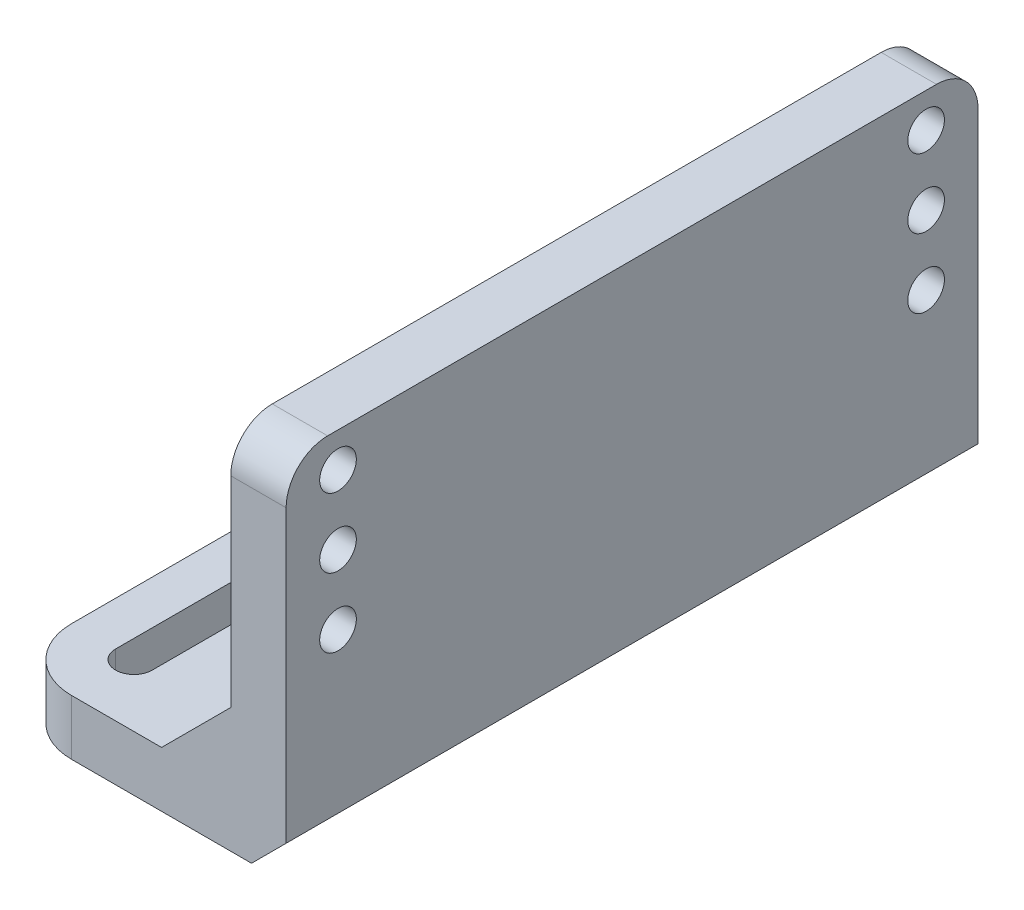
from build123d import *

# Parameters (mm, degrees)
SKETCH1_W           = 40
SKETCH1_H           = 100
BOSS_EXTRUDE1_DEPTH = 8
SKETCH2_W           = 100
SKETCH2_H           = 53
BOSS_EXTRUDE2_DEPTH = 8
SKETCH3_R           = 2.65
CUT_EXTRUDE1_DEPTH  = 9
FILLET1_R           = 6
CHAMFER2_SIZE       = 10
FILLET3_R           = 9
CUT_EXTRUDE3_DEPTH  = 9
CHAMFER1_SIZE       = 5


with BuildPart() as part:
    # Sketch1 → Boss-Extrude1 (new body)
    with BuildSketch(Plane(origin=(0, 0, 0), x_dir=(1, 0, 0), z_dir=(0, 1, 0))):
        with Locations((20, 50)):
            Rectangle(SKETCH1_W, SKETCH1_H)
    extrude(amount=BOSS_EXTRUDE1_DEPTH)

    # Sketch2 → Boss-Extrude2 (add)
    with BuildSketch(Plane.ZY):
        with Locations((-50, 26.5)):
            Rectangle(SKETCH2_W, SKETCH2_H)
    extrude(amount=-BOSS_EXTRUDE2_DEPTH)

    # Sketch3 → Cut-Extrude1 (cut, through all)
    with BuildSketch(Plane(origin=(8, 0, 0), x_dir=(0, 0, -1), z_dir=(1, 0, 0))):
        with Locations((7.5, 48)):
            Circle(SKETCH3_R)
        with Locations((92.5, 28)):
            Circle(SKETCH3_R)
        with Locations((92.5, 48)):
            Circle(SKETCH3_R)
        with Locations((92.5, 38)):
            Circle(SKETCH3_R)
        with Locations((7.5, 28)):
            Circle(SKETCH3_R)
        with Locations((7.5, 38)):
            Circle(SKETCH3_R)
    extrude(amount=-CUT_EXTRUDE1_DEPTH, mode=Mode.SUBTRACT)

    # Fillet1
    fillet1_edges = [part.edges().sort_by_distance(p)[0] for p in [
        (4, 53, 0),
        (4, 53, -100),
    ]]
    fillet(fillet1_edges, radius=FILLET1_R)

    # Chamfer2
    chamfer2_edges = [part.edges().sort_by_distance(p)[0] for p in [
        (8, 8, -50),
    ]]
    chamfer(chamfer2_edges, length=CHAMFER2_SIZE)

    # Fillet3
    fillet3_edges = [part.edges().sort_by_distance(p)[0] for p in [
        (40, 4, -100),
        (40, 4, 0),
    ]]
    fillet(fillet3_edges, radius=FILLET3_R)

    # Sketch5 → Cut-Extrude3 (cut, through all)
    with BuildSketch(Plane(origin=(0, 8, 0), x_dir=(1, 0, 0), z_dir=(0, 1, 0))):
        with BuildLine():
            Line((33.65, 91), (33.65, 66))
            ThreePointArc((33.65, 66), (31, 63.35), (28.35, 66))
            Line((28.35, 66), (28.35, 91))
            ThreePointArc((28.35, 91), (31, 93.65), (33.65, 91))
        make_face()
        with BuildLine():
            Line((33.65, 34), (33.65, 9))
            ThreePointArc((33.65, 9), (31, 6.35), (28.35, 9))
            Line((28.35, 9), (28.35, 34))
            ThreePointArc((28.35, 34), (31, 36.65), (33.65, 34))
        make_face()
    extrude(amount=-CUT_EXTRUDE3_DEPTH, mode=Mode.SUBTRACT)

    # Chamfer1
    chamfer1_edges = [part.edges().sort_by_distance(p)[0] for p in [
        (0, 0, -50),
    ]]
    chamfer(chamfer1_edges, length=CHAMFER1_SIZE)


with BuildPart() as body_2:
    # Mirror1: mirrored copy
    add(part.part.mirror(Plane(origin=(0, 8, 0), x_dir=(0, 0, 1), z_dir=(1, 0, 0))))


solid = body_2.part
